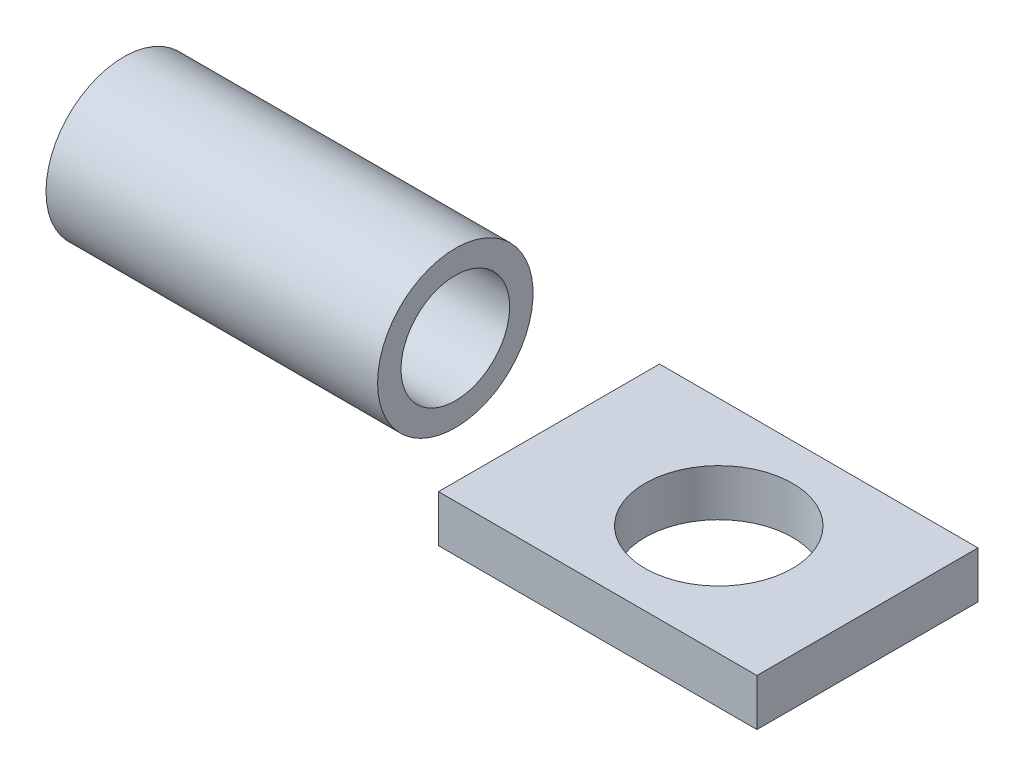
from build123d import *

# Parameters (mm, degrees)
SKETCH1_W           = 21.59
SKETCH1_H           = 14.986
SKETCH1_R           = 5
BOSS_EXTRUDE1_DEPTH = 3.175
SKETCH2_R           = 5.2705
SKETCH2_R_2         = 3.683
EXTRUDE_THIN1_DEPTH = 22.479


with BuildPart() as part:
    # Sketch1 → Boss-Extrude1 (new body)
    with BuildSketch(Plane(origin=(0, 0, 0), x_dir=(1, 0, 0), z_dir=(0, 1, 0))):
        with Locations((-0.715, 0)):
            Rectangle(SKETCH1_W, SKETCH1_H)
        Circle(SKETCH1_R, mode=Mode.SUBTRACT)
    extrude(amount=BOSS_EXTRUDE1_DEPTH)


with BuildPart() as body_2:
    # Sketch2 → Extrude-Thin1 (new body)
    with BuildSketch(Plane.ZY.offset(40.339)):
        with Locations((0, 5.2705)):
            Circle(SKETCH2_R)
        with Locations((0, 5.2705)):
            Circle(SKETCH2_R_2, mode=Mode.SUBTRACT)
    extrude(amount=-EXTRUDE_THIN1_DEPTH)


solid = Compound([part.part, body_2.part])
